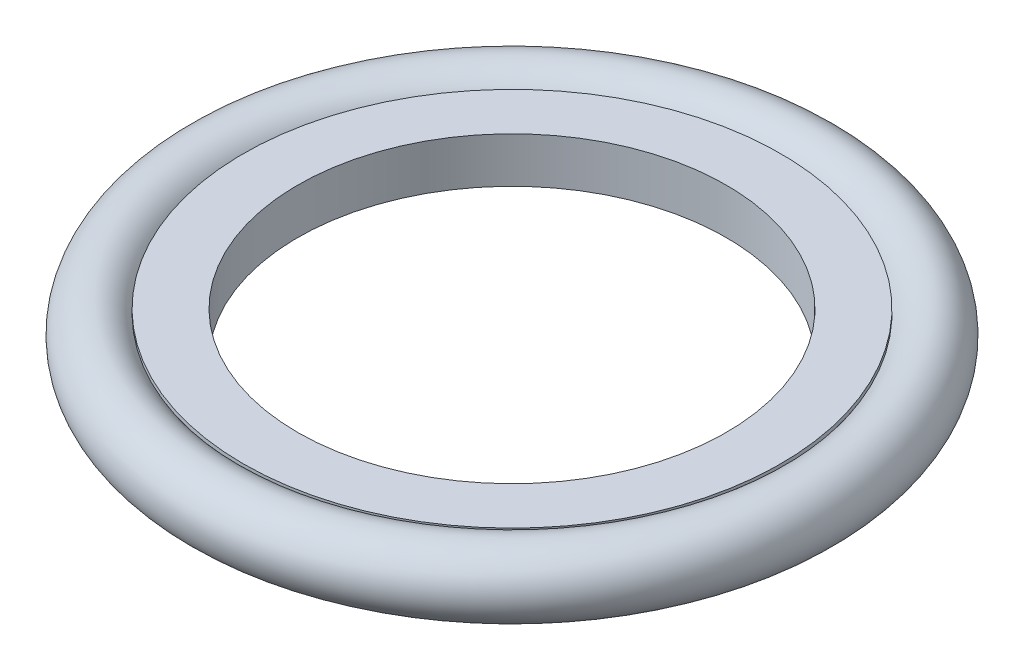
from build123d import *

# Parameters (mm, degrees)
SKETCH2_R = 25.655133929


with BuildPart() as part:
    # Sketch2 → Revolve2 (revolve)
    with BuildSketch(Plane(origin=(0, 0, 0), x_dir=(0, 0, -1), z_dir=(1, 0, 0))):
        with Locations((228.344866071, 0)):
            Circle(SKETCH2_R)
    revolve(axis=Axis((0, 0, 0), (0, -1, 0)))


with BuildPart() as body_2:
    # Sketch3 → Revolve3 (revolve)
    with BuildSketch(Plane(origin=(0, 0, 0), x_dir=(0, 0, -1), z_dir=(1, 0, 0))):
        Polygon((207.079055579, 17.526), (207.079055579, 14.351), (168.334198992, 14.351), (168.334198992, -14.351), (207.079055579, -14.351), (207.079055579, -17.526), (165.159198992, -17.526), (165.159198992, 17.526), align=None)
    revolve(axis=Axis((0, 0, 0), (0, -1, 0)))


solid = Compound([part.part, body_2.part])
